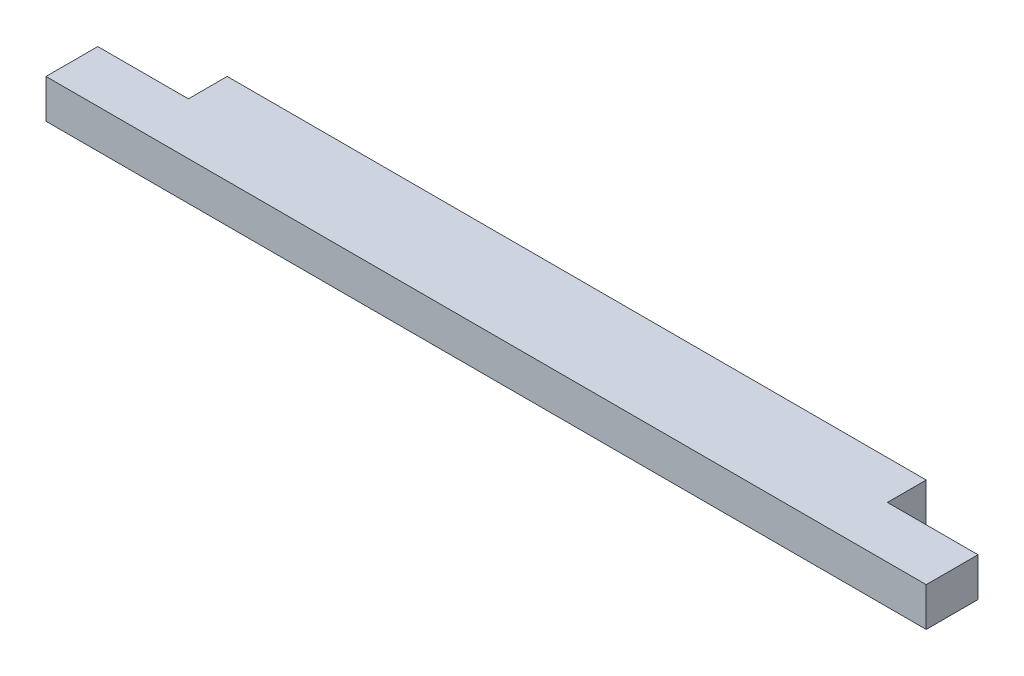
from build123d import *

# Parameters (mm, degrees)
SKETCH1_W           = 863.6
SKETCH1_H           = 88.9
BOSS_EXTRUDE1_DEPTH = 38.1
SKETCH3_W           = 88.9
SKETCH3_H           = 38.1
CUT_EXTRUDE1_DEPTH  = 39.1


with BuildPart() as part:
    # Sketch1 → Boss-Extrude1 (new body)
    with BuildSketch(Plane(origin=(0, 0, 0), x_dir=(1, 0, 0), z_dir=(0, 1, 0))):
        with Locations((431.8, 44.45)):
            Rectangle(SKETCH1_W, SKETCH1_H)
    extrude(amount=BOSS_EXTRUDE1_DEPTH)

    # Sketch3 → Cut-Extrude1 (cut, through all)
    with BuildSketch(Plane(origin=(0, 38.1, 0), x_dir=(1, 0, 0), z_dir=(0, 1, 0))):
        with Locations((44.45, 69.85)):
            Rectangle(SKETCH3_W, SKETCH3_H)
        with Locations((819.15, 69.85)):
            Rectangle(SKETCH3_W, SKETCH3_H)
    extrude(amount=-CUT_EXTRUDE1_DEPTH, mode=Mode.SUBTRACT)


solid = part.part
